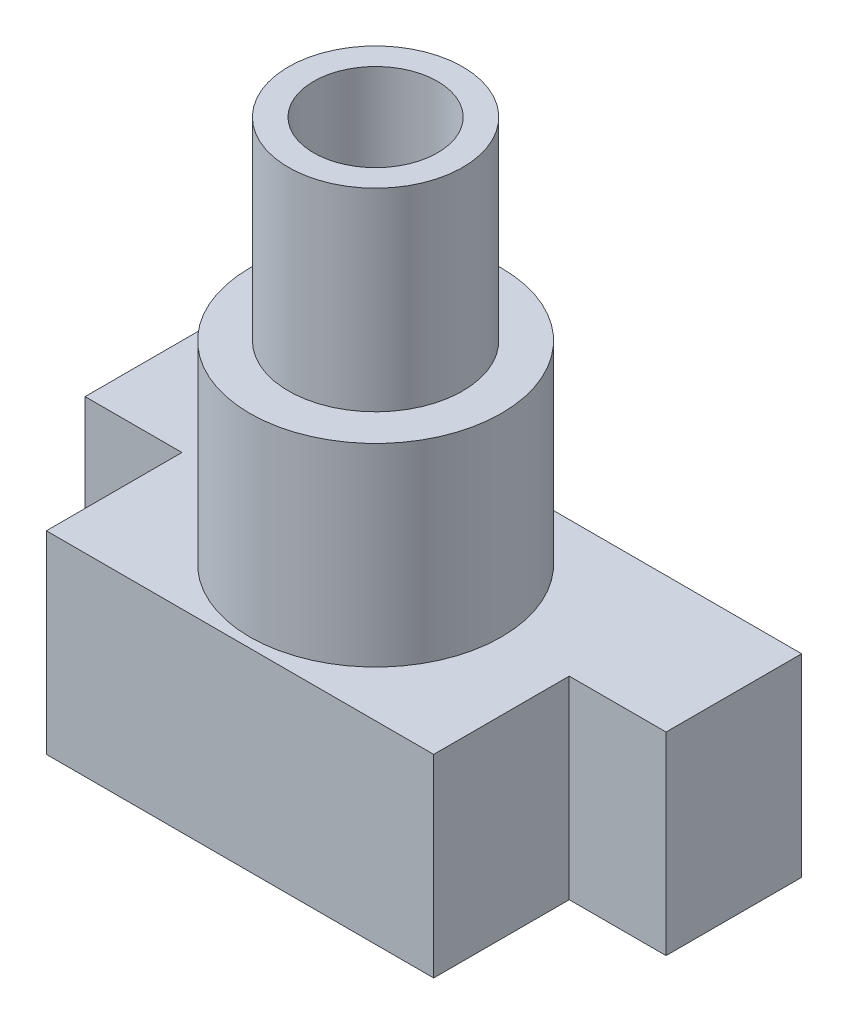
from build123d import *

# Parameters (mm, degrees)
BOSS_EXTRUDE1_DEPTH = 5
CUT_EXTRUDE1_DEPTH  = 2.5
SKETCH5_R           = 1.6
CUT_EXTRUDE2_DEPTH  = 13.5


with BuildPart() as part:
    # Sketch2 → Boss-Extrude1 (new body)
    with BuildSketch(Plane(origin=(0, 0, 0), x_dir=(1, 0, 0), z_dir=(0, 1, 0))):
        Polygon((-5, 0), (-7.5, 0), (-7.5, 3.5), (-5, 3.5), (5, 3.5), (7.5, 3.5), (7.5, 0), (5, 0), (5, -3.5), (-5, -3.5), align=None)
    extrude(amount=BOSS_EXTRUDE1_DEPTH)

    # Sketch3 → Cut-Extrude1 (cut)
    with BuildSketch(Plane.XZ):
        Polygon((3.175426481, 0), (1.58771324, 2.75), (-1.58771324, 2.75), (-3.175426481, 0), (-1.58771324, -2.75), (1.58771324, -2.75), align=None)
    extrude(amount=-CUT_EXTRUDE1_DEPTH, mode=Mode.SUBTRACT)

    # Sketch4 → Revolve1 (revolve)
    with BuildSketch(Plane.XY):
        Polygon((1.6, 5), (1.6, 15), (2.25, 15), (2.25, 10), (3.25, 10), (3.25, 5), align=None)
    revolve(axis=Axis((0, 0, 0), (0, 1, 0)))

    # Sketch5 → Cut-Extrude2 (cut, through all)
    with BuildSketch(Plane.XZ.offset(-2.5)):
        Circle(SKETCH5_R)
    extrude(amount=-CUT_EXTRUDE2_DEPTH, mode=Mode.SUBTRACT)


solid = part.part
